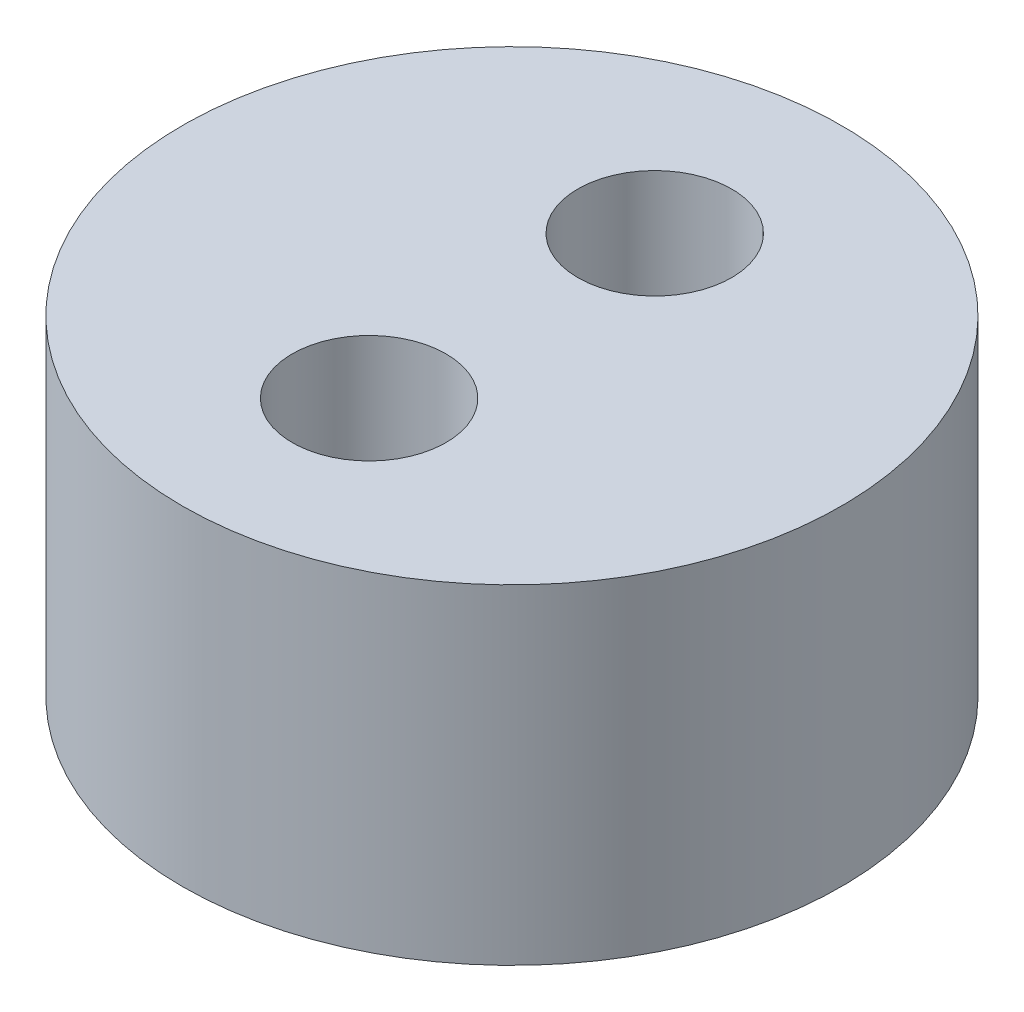
from build123d import *

# Parameters (mm, degrees)
SKETCH_1_R          = 3
EXTRUDE_1_DEPTH     = 3
SKETCH_2_R          = 0.7
CUT_EXTRUDE_1_DEPTH = 3


with BuildPart() as part:
    # 草图1 → 凸台-拉伸1 (new body)
    with BuildSketch(Plane(origin=(0, 0, 0), x_dir=(1, 0, 0), z_dir=(0, 1, 0))):
        Circle(SKETCH_1_R)
    extrude(amount=EXTRUDE_1_DEPTH)

    # 草图2 → 切除-拉伸1 (cut)
    with BuildSketch(Plane(origin=(0, 3, 0), x_dir=(1, 0, 0), z_dir=(0, 1, 0))):
        with Locations((0, 1.3)):
            Circle(SKETCH_2_R)
        with Locations((0, -1.3)):
            Circle(SKETCH_2_R)
    extrude(amount=-CUT_EXTRUDE_1_DEPTH, mode=Mode.SUBTRACT)


solid = part.part
